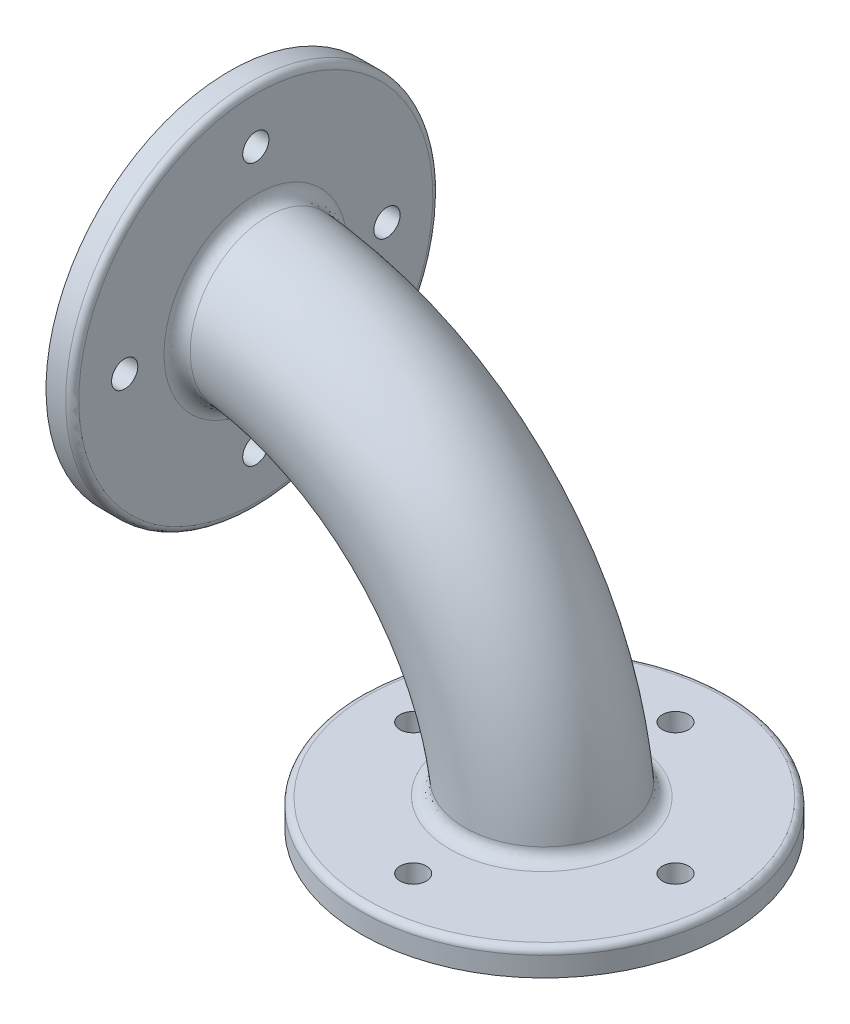
from build123d import *

# Parameters (mm, degrees)
SKETCH2_R           = 19.05
SKETCH2_R_2         = 12.7
SKETCH3_R           = 44.45
SKETCH3_R_2         = 3.175
SKETCH3_R_3         = 12.7
BOSS_EXTRUDE1_DEPTH = 6.35
FILLET1_R           = 3.175
FILLET2_R           = 1.5875


with BuildPart() as part:
    # Sweep1: sweep along a path in Sketch1
    with BuildLine(Plane.XY) as sweep1_path:
        ThreePointArc((0, 76.2), (53.881536726, 53.881536726), (76.2, 0))
    # Sketch2 → Sweep1 (sweep)
    with BuildSketch(Plane(origin=(0, 0, 0), x_dir=(1, 0, 0), z_dir=(0, 1, 0))):
        with Locations((76.2, 0)):
            Circle(SKETCH2_R)
        with Locations((76.2, 0)):
            Circle(SKETCH2_R_2, mode=Mode.SUBTRACT)
    sweep(path=sweep1_path.line)

    # Sketch3 → Boss-Extrude1 (add)
    with BuildSketch(Plane.XZ):
        with Locations((76.2, 0)):
            Circle(SKETCH3_R)
        with Locations((107.95, 0)):
            Circle(SKETCH3_R_2, mode=Mode.SUBTRACT)
        with Locations((76.2, -31.75)):
            Circle(SKETCH3_R_2, mode=Mode.SUBTRACT)
        with Locations((44.45, 0)):
            Circle(SKETCH3_R_2, mode=Mode.SUBTRACT)
        with Locations((76.2, 31.75)):
            Circle(SKETCH3_R_2, mode=Mode.SUBTRACT)
        with Locations((76.2, 0)):
            Circle(SKETCH3_R_3, mode=Mode.SUBTRACT)
    boss_extrude1 = extrude(amount=-BOSS_EXTRUDE1_DEPTH)

    # Mirror1: Boss-Extrude1 across plane
    add(boss_extrude1.mirror(Plane(origin=(0, 0, 0), x_dir=(0, 0, 1), z_dir=(-0.7071067811865488, 0.7071067811865464, 0))))

    # Fillet1
    fillet1_edges = [part.edges().sort_by_distance(p)[0] for p in [
        (56.796126628, 6.35, 0),
        (6.35, 56.796126628, 0),
    ]]
    fillet(fillet1_edges, radius=FILLET1_R)

    # Fillet2
    fillet2_edges = [part.edges().sort_by_distance(p)[0] for p in [
        (31.75, 6.35, 0),
        (6.35, 31.75, 0),
    ]]
    fillet(fillet2_edges, radius=FILLET2_R)


solid = part.part
